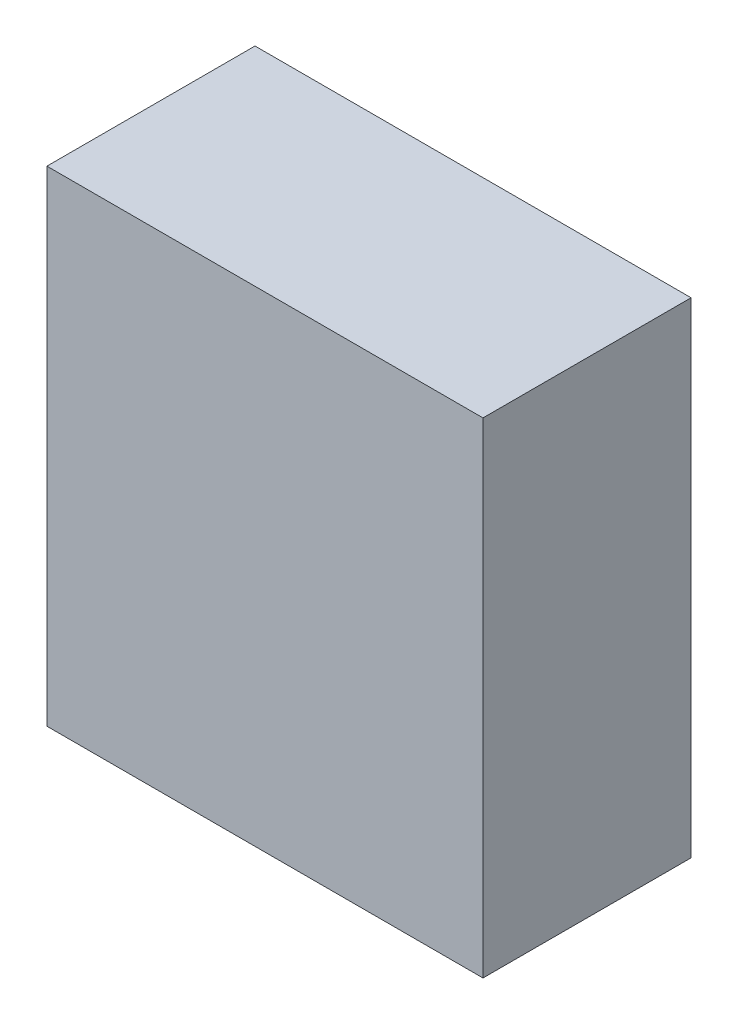
from build123d import *

# Parameters (mm, degrees)
SKETCH1_W           = 128.5875
SKETCH1_H           = 144.4625
BOSS_EXTRUDE1_DEPTH = 61.07176
SHELL1_T            = 6.35


with BuildPart() as part:
    # Sketch1 → Boss-Extrude1 (new body)
    with BuildSketch(Plane.XY):
        Rectangle(SKETCH1_W, SKETCH1_H)
    extrude(amount=-BOSS_EXTRUDE1_DEPTH)

    # Shell1
    shell1_openings = [part.faces().sort_by_distance(p)[0] for p in [
        (0, 0, -61.07176),
    ]]
    offset(amount=SHELL1_T, openings=shell1_openings, kind=Kind.INTERSECTION)


solid = part.part
